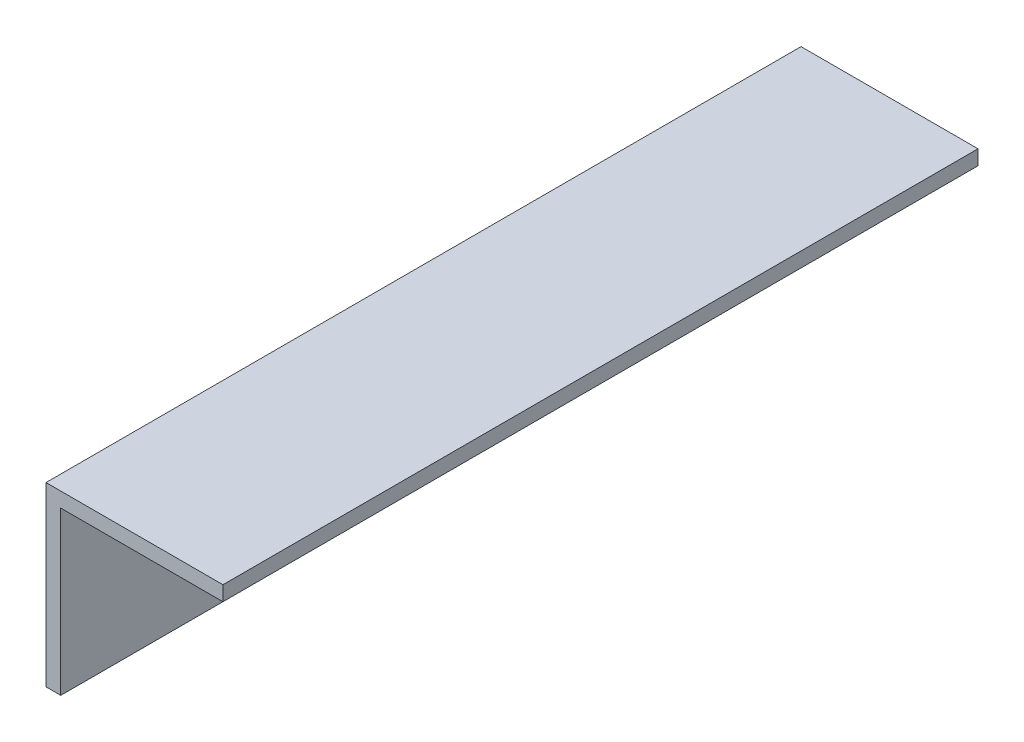
from build123d import *

# Parameters (mm, degrees)
BOSS_EXTRUDE1_DEPTH = 81.28


with BuildPart() as part:
    # Sketch1 → Boss-Extrude1 (new body)
    with BuildSketch(Plane.XY):
        Polygon((0, 0), (0, 19.05), (19.05, 19.05), (19.05, 17.4625), (1.5875, 17.4625), (1.5875, 0), align=None)
    extrude(amount=BOSS_EXTRUDE1_DEPTH)


solid = part.part
